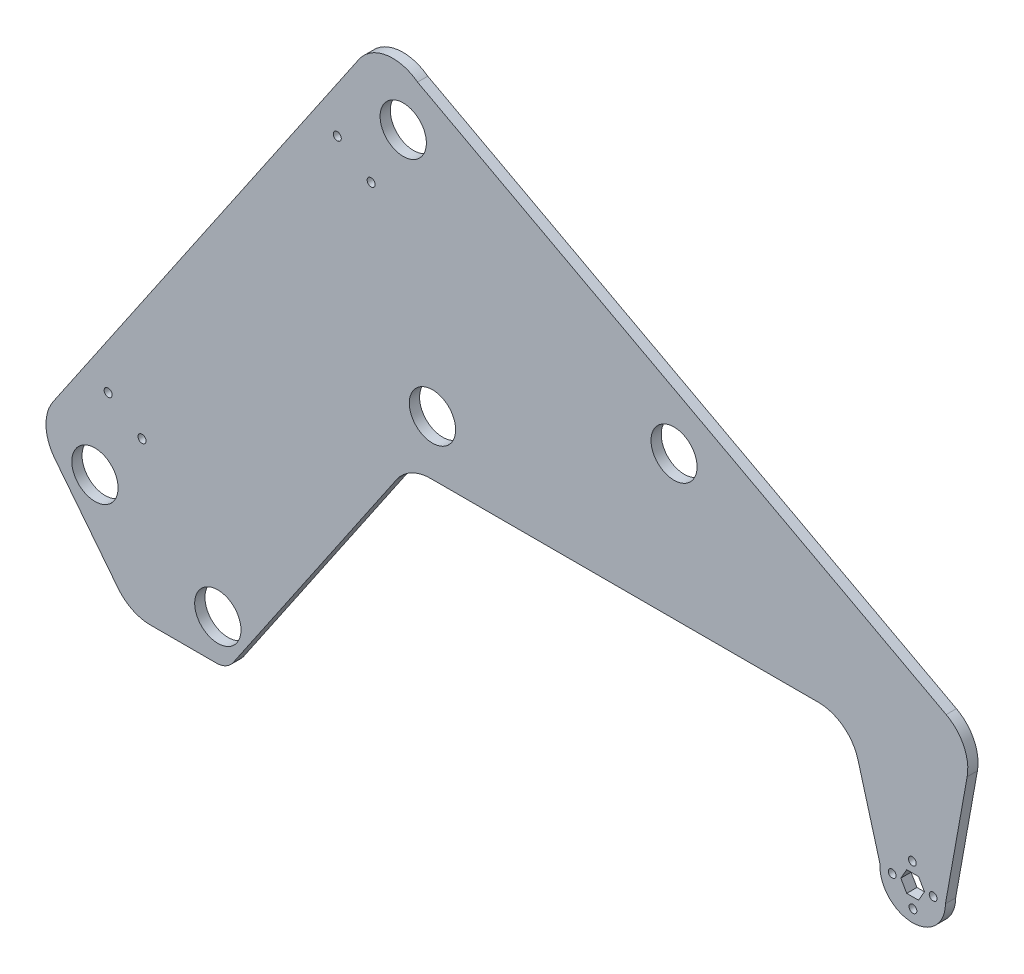
from build123d import *

# Parameters (mm, degrees)
MODEL_R             = 14.351
MODEL_R_2           = 2.413
MODEL_R_3           = 14.2875
BOSS_EXTRUDE1_DEPTH = 6.35
CUT_EXTRUDE1_REACH  = 8.35
SKETCH35_R          = 2.4892


with BuildPart() as part:
    # Model → Boss-Extrude1 (new body)
    with BuildSketch(Plane.XY):
        with BuildLine():
            ThreePointArc((-212.899365952, 93.541257838), (-203.778989185, 101.701881024), (-191.901103209, 104.650248016))
            Line((-191.901103209, 104.650248016), (48.661197018, 104.650248016))
            ThreePointArc((48.661197018, 104.650248016), (64.032332507, 99.471232012), (73.135172194, 86.046168785))
            Line((73.135172194, 86.046168785), (86.727013732, 37.098218434))
            ThreePointArc((86.727013732, 37.098218434), (106.36258142, 15.501750179), (127.326236921, 35.811553418))
            Line((127.326236921, 35.811553418), (140.807890588, 110.809453484))
            ThreePointArc((140.807890588, 110.809453484), (138.675228362, 126.361225539), (127.809114585, 137.689660276))
            Line((127.809114585, 137.689660276), (-44.466784077, 230.040741354))
            Line((-44.466784077, 230.040741354), (-154.507929168, 289.02994873))
            Line((-154.507929168, 289.02994873), (-199.949582693, 313.389629113))
            ThreePointArc((-199.949582693, 313.389629113), (-219.402189514, 318.224062751), (-236.303247901, 307.447705012))
            Line((-236.303247901, 307.447705012), (-425.920878295, 28.83612519))
            ThreePointArc((-425.920878295, 28.83612519), (-430.307847502, 13.679090678), (-424.898106806, -1.143726181))
            Line((-424.898106806, -1.143726181), (-385.58146606, -51.20282143))
            ThreePointArc((-385.58146606, -51.20282143), (-376.71145599, -58.357541068), (-365.605974805, -60.913979882))
            Line((-365.605974805, -60.913979882), (-324.737451002, -60.913979882))
            ThreePointArc((-324.737451002, -60.913979882), (-318.798508014, -59.439796386), (-314.23831963, -55.359484793))
            Line((-314.23831963, -55.359484793), (-212.899365952, 93.541257838))
        make_face()
        with Locations((-323.775189267, -35.513979882)):
            Circle(MODEL_R, mode=Mode.SUBTRACT)
        with Locations((-399.975189267, 2.586020118)):
            Circle(MODEL_R, mode=Mode.SUBTRACT)
        with Locations((107.189078625, 23.111553418)):
            Circle(MODEL_R_2, mode=Mode.SUBTRACT)
        with Locations((94.306236921, 35.628711714)):
            Circle(MODEL_R_2, mode=Mode.SUBTRACT)
        Polygon((110.67241113, 42.161553418), (114.338585339, 35.811553418), (110.67241113, 29.461553418), (103.340062711, 29.461553418), (99.673888502, 35.811553418), (103.340062711, 42.161553418), (106.823395217, 42.161553418), align=None, mode=Mode.SUBTRACT)
        with Locations((119.706236921, 35.994395122)):
            Circle(MODEL_R_2, mode=Mode.SUBTRACT)
        with Locations((106.823395217, 48.511553418)):
            Circle(MODEL_R_2, mode=Mode.SUBTRACT)
        with Locations((-190.707148919, 138.516914683)):
            Circle(MODEL_R, mode=Mode.SUBTRACT)
        with Locations((-208.832932893, 283.437784316)):
            Circle(MODEL_R, mode=Mode.SUBTRACT)
        with Locations((-40.935516122, 193.433854171)):
            Circle(MODEL_R_3, mode=Mode.SUBTRACT)
    extrude(amount=BOSS_EXTRUDE1_DEPTH)

    # Sketch35 → Cut-Extrude1 (cut, up to next)
    with BuildSketch(Plane.XY.offset(6.35), mode=Mode.PRIVATE) as cut_extrude1_sk1:
        with Locations((-391.784122689, 50.779120634)):
            Circle(SKETCH35_R)
    cut_extrude1_tool1 = extrude(cut_extrude1_sk1.sketch, amount=-CUT_EXTRUDE1_REACH, mode=Mode.PRIVATE) & part.part
    add(cut_extrude1_tool1.solids().sort_by_distance((-391.784123, 50.779121, 6.35))[0], mode=Mode.SUBTRACT)
    # Sketch35 → Cut-Extrude1 (cut, up to next)
    with BuildSketch(Plane.XY.offset(6.35), mode=Mode.PRIVATE) as cut_extrude1_sk2:
        with Locations((-249.731485055, 259.501852308)):
            Circle(SKETCH35_R)
    cut_extrude1_tool2 = extrude(cut_extrude1_sk2.sketch, amount=-CUT_EXTRUDE1_REACH, mode=Mode.PRIVATE) & part.part
    add(cut_extrude1_tool2.solids().sort_by_distance((-249.731485, 259.501852, 6.35))[0], mode=Mode.SUBTRACT)
    # Sketch35 → Cut-Extrude1 (cut, up to next)
    with BuildSketch(Plane.XY.offset(6.35), mode=Mode.PRIVATE) as cut_extrude1_sk3:
        with Locations((-228.733222311, 245.210842485)):
            Circle(SKETCH35_R)
    cut_extrude1_tool3 = extrude(cut_extrude1_sk3.sketch, amount=-CUT_EXTRUDE1_REACH, mode=Mode.PRIVATE) & part.part
    add(cut_extrude1_tool3.solids().sort_by_distance((-228.733222, 245.210842, 6.35))[0], mode=Mode.SUBTRACT)
    # Sketch35 → Cut-Extrude1 (cut, up to next)
    with BuildSketch(Plane.XY.offset(6.35), mode=Mode.PRIVATE) as cut_extrude1_sk4:
        with Locations((-370.785859945, 36.488110812)):
            Circle(SKETCH35_R)
    cut_extrude1_tool4 = extrude(cut_extrude1_sk4.sketch, amount=-CUT_EXTRUDE1_REACH, mode=Mode.PRIVATE) & part.part
    add(cut_extrude1_tool4.solids().sort_by_distance((-370.78586, 36.488111, 6.35))[0], mode=Mode.SUBTRACT)


solid = part.part
